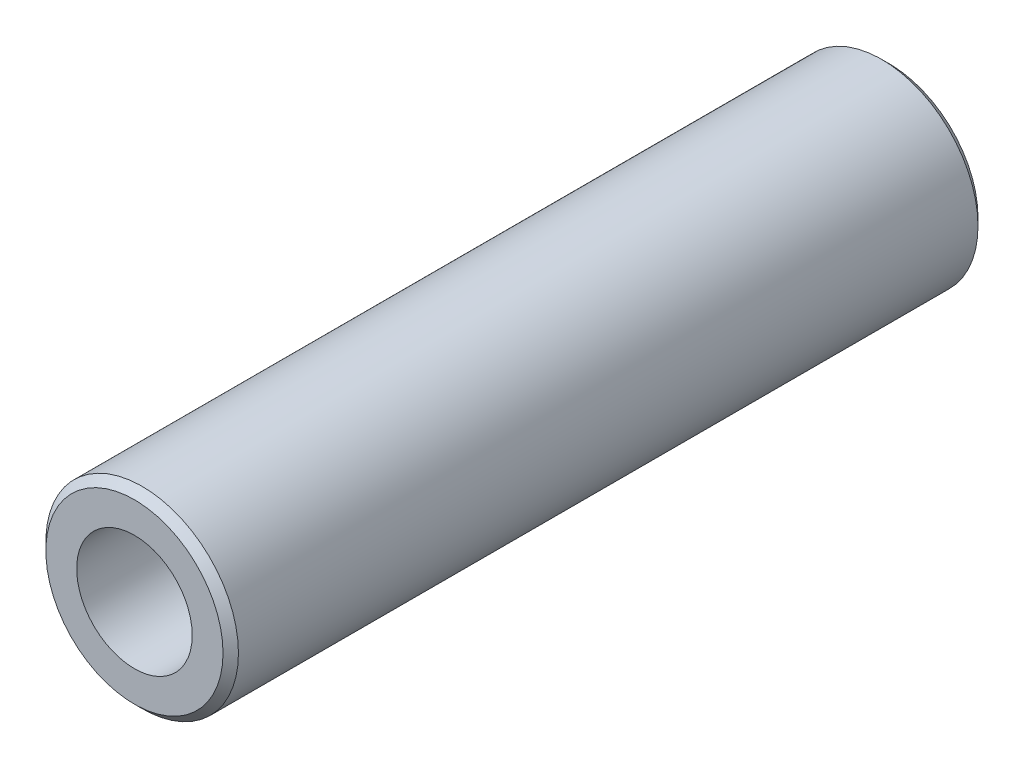
from build123d import *

# Parameters (mm, degrees)
SKETCH1_R           = 158.75
SKETCH1_R_2         = 95.25
EXTRUDE_THIN1_DEPTH = 1244.6
CHAMFER1_SIZE       = 12.7


with BuildPart() as part:
    # Sketch1 → Extrude-Thin1 (new body)
    with BuildSketch(Plane.XY):
        Circle(SKETCH1_R)
        Circle(SKETCH1_R_2, mode=Mode.SUBTRACT)
    extrude(amount=EXTRUDE_THIN1_DEPTH)

    # Chamfer1
    chamfer1_edges = [part.edges().sort_by_distance(p)[0] for p in [
        (-158.75, 0, 0),
        (-158.75, 0, 1244.6),
    ]]
    chamfer(chamfer1_edges, length=CHAMFER1_SIZE)


solid = part.part
